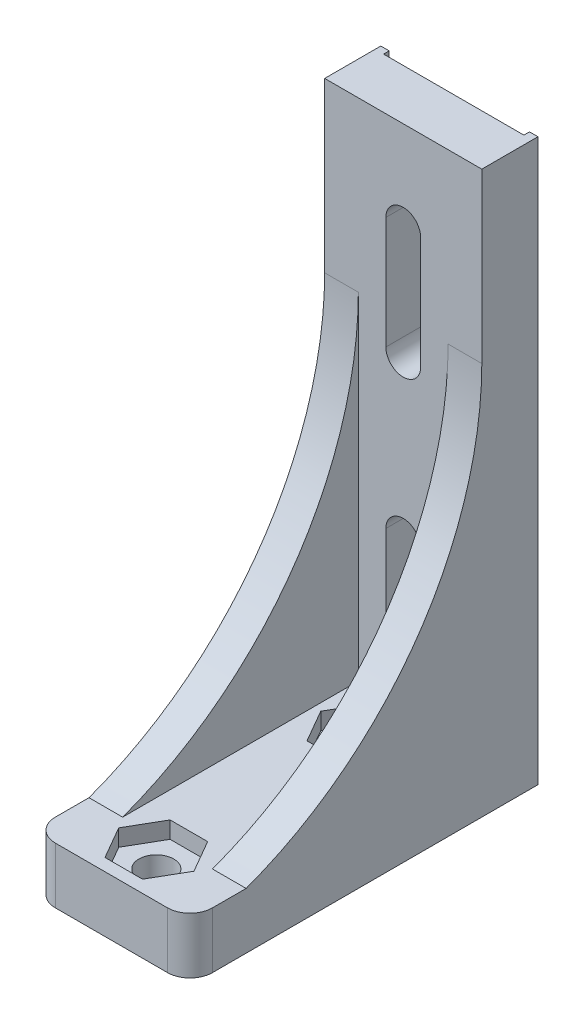
from build123d import *

# Parameters (mm, degrees)
CROQUIS2_W              = 14
CROQUIS2_H              = 31
CROQUIS2_R              = 1.55
SALIENTE_EXTRUIR1_DEPTH = 50
CROQUIS3_W              = 26
CROQUIS3_H              = 45
CORTAR_EXTRUIR1_DEPTH   = 14
CORTAR_EXTRUIR2_DEPTH   = 5
CORTAR_EXTRUIR3_DEPTH   = 1.5
SALIENTE_EXTRUIR3_DEPTH = 14
CROQUIS7_OUTSIDE_W      = 28.094
CROQUIS7_OUTSIDE_H      = 45.094
CORTAR_EXTRUIR5_DEPTH   = 45
REDONDEO1_R             = 2
CROQUIS8_W              = 12.5
CROQUIS8_H              = 0.5
CORTAR_EXTRUIR6_DEPTH   = 50


with BuildPart() as part:
    # Croquis2 → Saliente-Extruir1 (new body)
    with BuildSketch(Plane(origin=(0, 0, 0), x_dir=(1, 0, 0), z_dir=(0, 1, 0))):
        with Locations((7, 15.5)):
            Rectangle(CROQUIS2_W, CROQUIS2_H)
        with Locations((7, 22)):
            Circle(CROQUIS2_R, mode=Mode.SUBTRACT)
        with Locations((7, 4)):
            Circle(CROQUIS2_R, mode=Mode.SUBTRACT)
    extrude(amount=SALIENTE_EXTRUIR1_DEPTH)

    # Croquis3 → Cortar-Extruir1 (cut)
    with BuildSketch(Plane.ZY):
        with Locations((-13, 27.5)):
            Rectangle(CROQUIS3_W, CROQUIS3_H)
    extrude(amount=-CORTAR_EXTRUIR1_DEPTH, mode=Mode.SUBTRACT)

    # Croquis4 → Cortar-Extruir2 (cut)
    with BuildSketch(Plane(origin=(0, 0, -31), x_dir=(-1, 0, 0), z_dir=(0, 0, -1))):
        with BuildLine():
            Line((-8.55, 8), (-8.55, 18))
            ThreePointArc((-8.55, 18), (-7, 19.55), (-5.45, 18))
            Line((-5.45, 18), (-5.45, 8))
            ThreePointArc((-5.45, 8), (-7, 6.45), (-8.55, 8))
        make_face()
        with BuildLine():
            Line((-8.55, 32), (-8.55, 42))
            ThreePointArc((-8.55, 42), (-7, 43.55), (-5.45, 42))
            Line((-5.45, 42), (-5.45, 32))
            ThreePointArc((-5.45, 32), (-7, 30.45), (-8.55, 32))
        make_face()
    extrude(amount=-CORTAR_EXTRUIR2_DEPTH, mode=Mode.SUBTRACT)

    # Croquis5 → Cortar-Extruir3 (cut)
    with BuildSketch(Plane(origin=(0, 5, 0), x_dir=(1, 0, 0), z_dir=(0, 1, 0))):
        Polygon((10.348631561, 4), (8.674315781, 6.9), (5.325684219, 6.9), (3.651368439, 4), (5.325684219, 1.1), (8.674315781, 1.1), align=None)
        Polygon((8.674315781, 19.1), (10.348631561, 22), (8.674315781, 24.9), (5.325684219, 24.9), (3.651368439, 22), (5.325684219, 19.1), align=None)
    extrude(amount=-CORTAR_EXTRUIR3_DEPTH, mode=Mode.SUBTRACT)

    # Croquis6 → Saliente-Extruir3 (add)
    with BuildSketch(Plane.ZY):
        with BuildLine():
            Line((-26, 5), (-26, 35))
            ThreePointArc((-26, 35), (-20.21590319, 16.698867767), (-5, 5))
            Line((-5, 5), (-26, 5))
        make_face()
    extrude(amount=-SALIENTE_EXTRUIR3_DEPTH)

    # Croquis7 outside → Cortar-Extruir5 (cut)
    with BuildSketch(Plane(origin=(0, 50, 0), x_dir=(1, 0, 0), z_dir=(0, 1, 0))):
        with Locations((7, 15.5)):
            Rectangle(CROQUIS7_OUTSIDE_W, CROQUIS7_OUTSIDE_H)
        Polygon((0, 26), (0, 0), (3, 0), (3, 26), (11, 26), (11, 0), (14, 0), (14, 26), (14, 31), (0, 31), align=None, mode=Mode.SUBTRACT)
    extrude(amount=-CORTAR_EXTRUIR5_DEPTH, mode=Mode.SUBTRACT)

    # Redondeo1
    redondeo1_edges = [part.edges().sort_by_distance(p)[0] for p in [
        (14, 2.5, 0),
        (0, 2.5, 0),
    ]]
    fillet(redondeo1_edges, radius=REDONDEO1_R)

    # Croquis8 → Cortar-Extruir6 (cut)
    with BuildSketch(Plane(origin=(0, 50, 0), x_dir=(1, 0, 0), z_dir=(0, 1, 0))):
        with Locations((7, 30.75)):
            Rectangle(CROQUIS8_W, CROQUIS8_H)
    extrude(amount=-CORTAR_EXTRUIR6_DEPTH, mode=Mode.SUBTRACT)


solid = part.part
